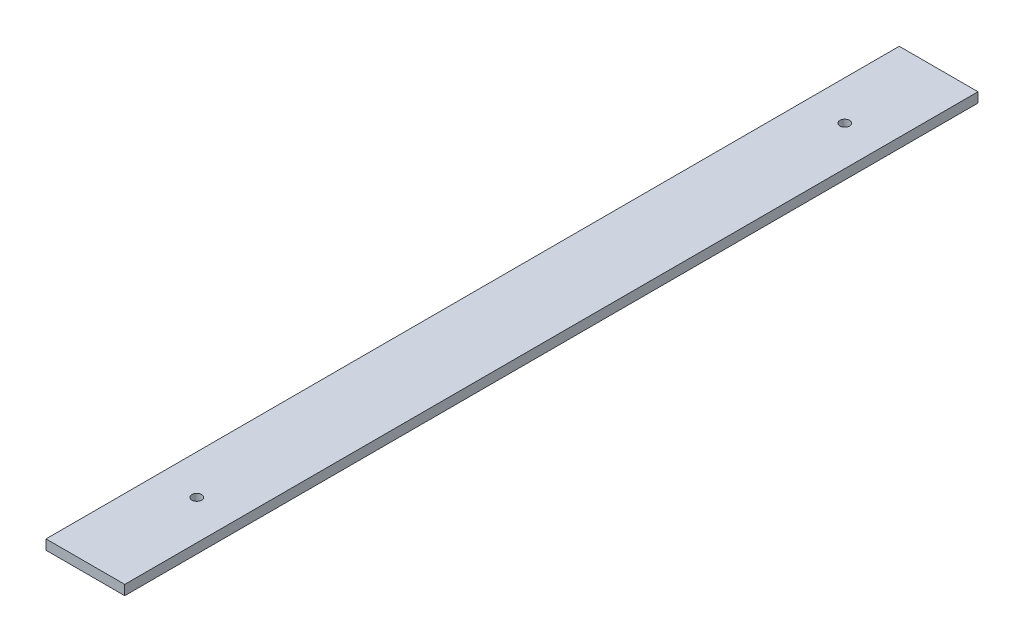
from build123d import *

# Parameters (mm, degrees)
SKETCH4_W             = 200
SKETCH4_H             = 2933.573874127
SKETCH4_R             = 12.5
BOSS_EXTRUDE1_DEPTH   = 25
SKETCH4_H_2           = 2891.000919938
BOSS_EXTRUDE1_2_DEPTH = 25
SKETCH4_H_3           = 2656.8496719
BOSS_EXTRUDE1_3_DEPTH = 25
SKETCH4_H_4           = 2167.26069873
BOSS_EXTRUDE1_4_DEPTH = 25
SKETCH4_H_5           = 1693.636583381
BOSS_EXTRUDE1_5_DEPTH = 25
SKETCH5_W             = 1339.509446366
SKETCH5_H             = 4935.034802403
SKETCH5_W_2           = 4846.909180931
SKETCH5_H_2           = 7014.799469129
SKETCH5_W_3           = 493.50348024
SKETCH5_H_3           = 881.256214715
CUT_EXTRUDE1_DEPTH    = 26


with BuildPart() as part:
    # Sketch4 → Boss-Extrude1 (new body)
    with BuildSketch(Plane(origin=(0, 0, 0), x_dir=(1, 0, 0), z_dir=(0, 1, 0))):
        with Locations((23132.944645813, -11409.369811035)):
            Rectangle(SKETCH4_W, SKETCH4_H)
        with Locations((23132.944645813, -12678.089615367)):
            Circle(SKETCH4_R, mode=Mode.SUBTRACT)
        with Locations((23132.944645813, -10181.030459334)):
            Circle(SKETCH4_R, mode=Mode.SUBTRACT)
    extrude(amount=BOSS_EXTRUDE1_DEPTH)


with BuildPart() as body_2:
    # Sketch4 → Boss-Extrude1 2 (new body)
    with BuildSketch(Plane(origin=(0, 0, 0), x_dir=(1, 0, 0), z_dir=(0, 1, 0))):
        with Locations((22032.944645813, -11388.083333941)):
            Rectangle(SKETCH4_W, SKETCH4_H_2)
        with Locations((22032.944645813, -12621.228285175)):
            Circle(SKETCH4_R, mode=Mode.SUBTRACT)
        with Locations((22032.944645813, -10181.030459334)):
            Circle(SKETCH4_R, mode=Mode.SUBTRACT)
    extrude(amount=BOSS_EXTRUDE1_2_DEPTH)


with BuildPart() as body_3:
    # Sketch4 → Boss-Extrude1 3 (new body)
    with BuildSketch(Plane(origin=(0, 0, 0), x_dir=(1, 0, 0), z_dir=(0, 1, 0))):
        with Locations((20832.944645813, -11271.007709922)):
            Rectangle(SKETCH4_W, SKETCH4_H_3)
        with Locations((20832.944645813, -12348.754240871)):
            Circle(SKETCH4_R, mode=Mode.SUBTRACT)
        with Locations((20832.944645813, -10181.030459334)):
            Circle(SKETCH4_R, mode=Mode.SUBTRACT)
    extrude(amount=BOSS_EXTRUDE1_3_DEPTH)


with BuildPart() as body_4:
    # Sketch4 → Boss-Extrude1 4 (new body)
    with BuildSketch(Plane(origin=(0, 0, 0), x_dir=(1, 0, 0), z_dir=(0, 1, 0))):
        with Locations((19632.944645813, -11026.213223337)):
            Rectangle(SKETCH4_W, SKETCH4_H_4)
        with Locations((19632.944645813, -11826.915448153)):
            Circle(SKETCH4_R, mode=Mode.SUBTRACT)
        with Locations((19632.944645813, -10181.030459334)):
            Circle(SKETCH4_R, mode=Mode.SUBTRACT)
    extrude(amount=BOSS_EXTRUDE1_4_DEPTH)


with BuildPart() as body_5:
    # Sketch4 → Boss-Extrude1 5 (new body)
    with BuildSketch(Plane(origin=(0, 0, 0), x_dir=(1, 0, 0), z_dir=(0, 1, 0))):
        with Locations((18802.944645813, -10789.401165663)):
            Rectangle(SKETCH4_W, SKETCH4_H_5)
        with Locations((18802.944645813, -11283.669778774)):
            Circle(SKETCH4_R, mode=Mode.SUBTRACT)
        with Locations((18802.944645813, -10181.030459334)):
            Circle(SKETCH4_R, mode=Mode.SUBTRACT)
    extrude(amount=BOSS_EXTRUDE1_5_DEPTH)


with BuildPart() as cut_extrude1_tool:
    # Sketch5 → Cut-Extrude1 (new body, through all)
    with BuildSketch(Plane(origin=(0, 0, 0), x_dir=(1, 0, 0), z_dir=(0, 1, 0))):
        with Locations((18465.176996023, -10818.928147177)):
            Rectangle(SKETCH5_W, SKETCH5_H)
        with Locations((22474.892772976, -10995.17939012)):
            Rectangle(SKETCH5_W_2, SKETCH5_H_2)
        with Locations((20474.441165573, -13427.446542733)):
            Rectangle(SKETCH5_W_3, SKETCH5_H_3, mode=Mode.SUBTRACT)
    extrude(amount=CUT_EXTRUDE1_DEPTH)


with BuildPart() as part_1:
    add(part.part)

    # Cut-Extrude1: cut by cut_extrude1_tool
    add(cut_extrude1_tool.part, mode=Mode.SUBTRACT)


with BuildPart() as body_2_1:
    add(body_2.part)

    # Cut-Extrude1: cut by cut_extrude1_tool
    add(cut_extrude1_tool.part, mode=Mode.SUBTRACT)


with BuildPart() as body_3_1:
    add(body_3.part)

    # Cut-Extrude1: cut by cut_extrude1_tool
    add(cut_extrude1_tool.part, mode=Mode.SUBTRACT)


with BuildPart() as body_5_1:
    add(body_5.part)

    # Cut-Extrude1: cut by cut_extrude1_tool
    add(cut_extrude1_tool.part, mode=Mode.SUBTRACT)


solid = body_4.part
